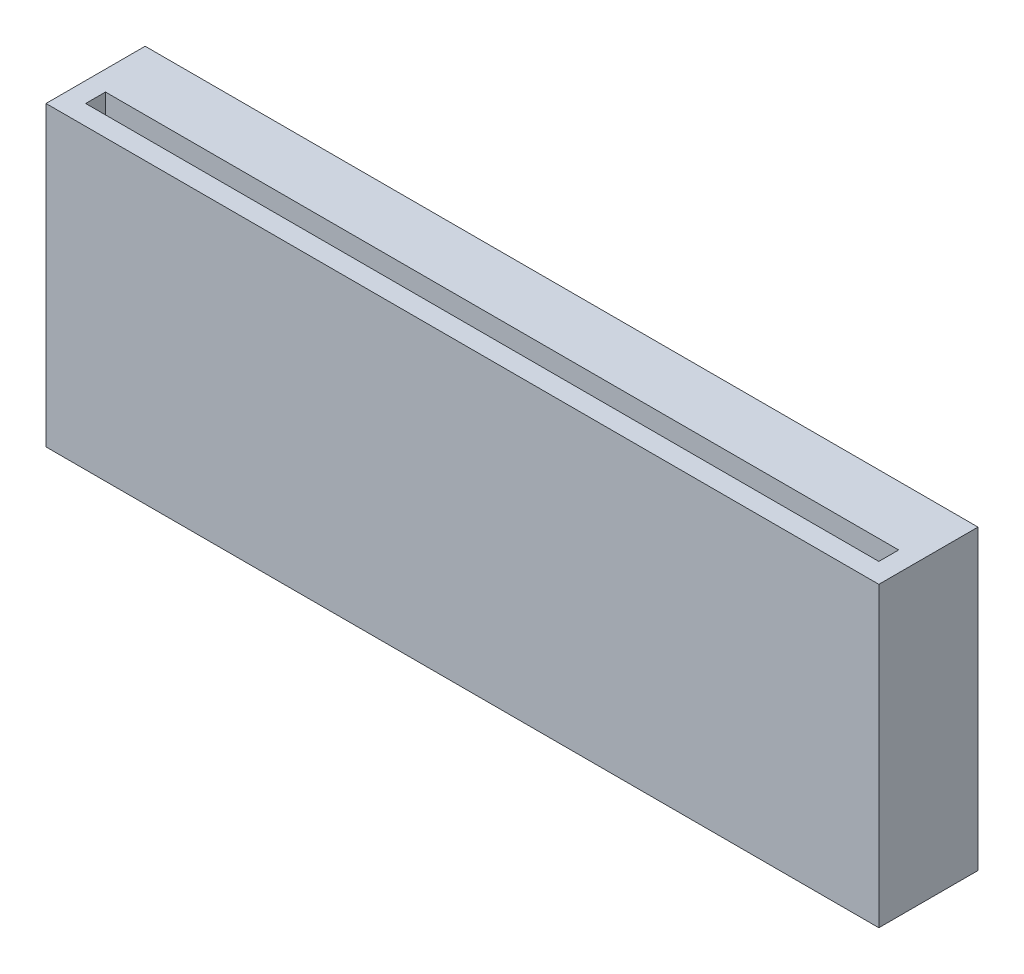
from build123d import *

# Parameters (mm, degrees)
SKETCH1_W           = 40
SKETCH1_H           = 15
BOSS_EXTRUDE1_DEPTH = 5
BOSS_EXTRUDE2_DEPTH = 7.5
SKETCH3_W           = 5
SKETCH3_H           = 15
BOSS_EXTRUDE3_DEPTH = 1
SKETCH4_W           = 40
SKETCH4_H           = 1
CUT_EXTRUDE1_DEPTH  = 12


with BuildPart() as part:
    # Sketch1 → Boss-Extrude1 (new body)
    with BuildSketch(Plane.XY):
        with Locations((-20, 7.5)):
            Rectangle(SKETCH1_W, SKETCH1_H)
    extrude(amount=BOSS_EXTRUDE1_DEPTH)

    # Sketch2 → Boss-Extrude2 (add)
    with BuildSketch(Plane.XZ):
        Polygon((-8, 0), (-12, 0), (-12, -2.5), (-14.5, -2.5), (-14.5, -3.5), (-12, -6), (-8, -6), (-5.5, -3.5), (-5.5, -2.5), (-8, -2.5), align=None)
    boss_extrude2 = extrude(amount=-BOSS_EXTRUDE2_DEPTH)

    # Mirror1: Boss-Extrude2 across plane
    add(boss_extrude2.mirror(Plane(origin=(-20, 0, 0), x_dir=(0, 0, 1), z_dir=(1, 0, 0))))

    # Sketch3 → Boss-Extrude3 (add)
    with BuildSketch(Plane(origin=(0, 0, 0), x_dir=(0, 0, -1), z_dir=(1, 0, 0))):
        with Locations((-2.5, 7.5)):
            Rectangle(SKETCH3_W, SKETCH3_H)
    boss_extrude3 = extrude(amount=BOSS_EXTRUDE3_DEPTH)

    # Mirror2: Boss-Extrude3 across plane
    add(boss_extrude3.mirror(Plane(origin=(-20, 0, 0), x_dir=(0, 0, 1), z_dir=(1, 0, 0))))

    # Sketch4 → Cut-Extrude1 (cut)
    with BuildSketch(Plane(origin=(0, 15, 0), x_dir=(1, 0, 0), z_dir=(0, 1, 0))):
        with Locations((-20, -3.5)):
            Rectangle(SKETCH4_W, SKETCH4_H)
    extrude(amount=-CUT_EXTRUDE1_DEPTH, mode=Mode.SUBTRACT)


solid = part.part
